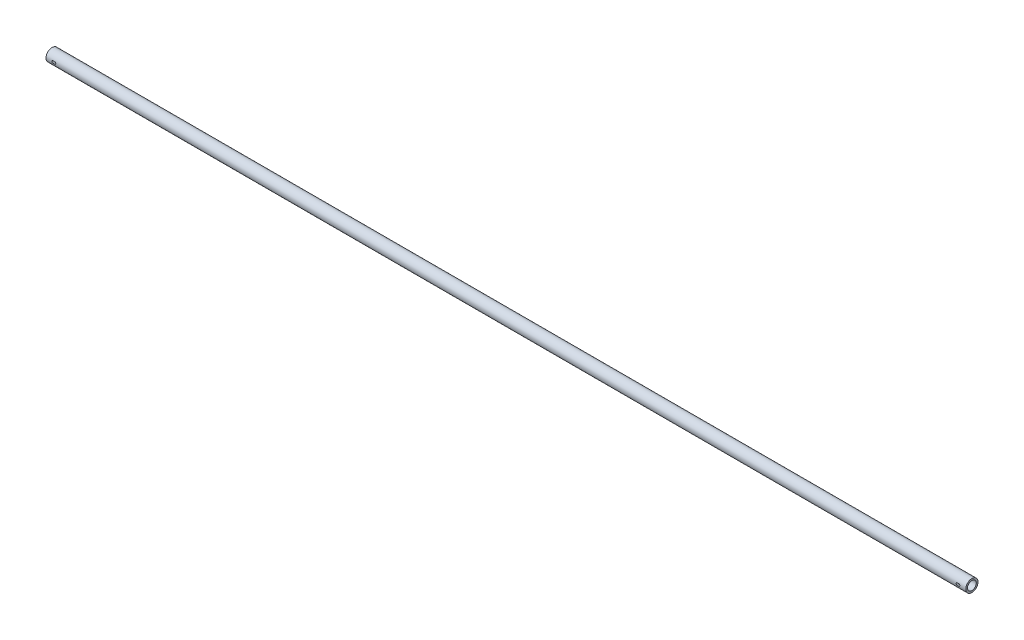
from build123d import *

# Parameters (mm, degrees)
SKETCH_1_R          = 17.5
SKETCH_1_R_2        = 12
EXTRUDE_1_DEPTH     = 2636
SKETCH_2_R          = 12.6
CUT_EXTRUDE_1_DEPTH = 52
SKETCH_3_R          = 12.6
CUT_EXTRUDE_2_DEPTH = 52
CUT_EXTRUDE_3_DEPTH = 20
CUT_EXTRUDE_4_DEPTH = 20


with BuildPart() as part:
    # 草图1 → 凸台-拉伸1 (new body)
    with BuildSketch(Plane(origin=(0, 0, 0), x_dir=(0, 0, -1), z_dir=(1, 0, 0))):
        Circle(SKETCH_1_R)
        Circle(SKETCH_1_R_2, mode=Mode.SUBTRACT)
    extrude(amount=EXTRUDE_1_DEPTH)

    # 草图2 → 切除-拉伸1 (cut)
    with BuildSketch(Plane.ZY):
        Circle(SKETCH_2_R)
    extrude(amount=-CUT_EXTRUDE_1_DEPTH, mode=Mode.SUBTRACT)

    # 草图3 → 切除-拉伸2 (cut)
    with BuildSketch(Plane(origin=(2636, 0, 0), x_dir=(0, 0, -1), z_dir=(1, 0, 0))):
        Circle(SKETCH_3_R)
    extrude(amount=-CUT_EXTRUDE_2_DEPTH, mode=Mode.SUBTRACT)

    # 草图4 → 切除-拉伸3 (cut, symmetric)
    with BuildSketch(Plane.XY):
        with BuildLine():
            Line((20, 3), (25, 3))
            ThreePointArc((25, 3), (28, 0), (25, -3))
            Line((25, -3), (20, -3))
            ThreePointArc((20, -3), (17, 0), (20, 3))
        make_face()
    extrude(amount=CUT_EXTRUDE_3_DEPTH, both=True, mode=Mode.SUBTRACT)

    # 草图5 → 切除-拉伸4 (cut, symmetric)
    with BuildSketch(Plane.XY):
        with BuildLine():
            Line((2611, 3), (2616, 3))
            ThreePointArc((2616, 3), (2619, 0), (2616, -3))
            Line((2616, -3), (2611, -3))
            ThreePointArc((2611, -3), (2608, 0), (2611, 3))
        make_face()
    extrude(amount=CUT_EXTRUDE_4_DEPTH, both=True, mode=Mode.SUBTRACT)


solid = part.part
